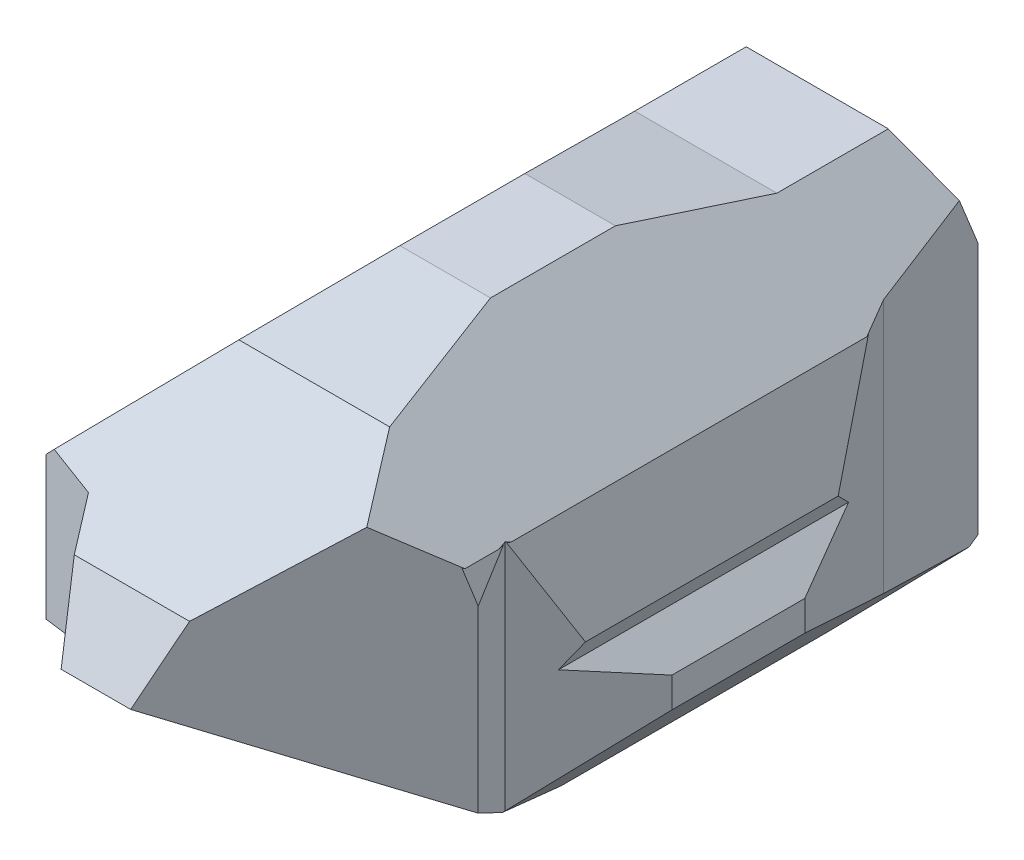
from build123d import *

# Parameters (mm, degrees)
ESQUISSE1_W              = 15
ESQUISSE1_H              = 15
BOSS_EXTRU_1_DEPTH       = 30
ENL_V_MAT_EXTRU_1_DEPTH  = 30
ENL_V_MAT_EXTRU_2_DEPTH  = 30
ENL_V_MAT_EXTRU_3_DEPTH  = 30
ENL_V_MAT_EXTRU_5_DEPTH  = 30
ENL_V_MAT_EXTRU_7_DEPTH  = 30
ENL_V_MAT_EXTRU_8_DEPTH  = 30
ENL_V_MAT_EXTRU_13_DEPTH = 30
ENL_V_MAT_EXTRU_15_DEPTH = 30
ENL_V_MAT_EXTRU_16_DEPTH = 30
ENL_V_MAT_EXTRU_17_DEPTH = 30
ENL_V_MAT_EXTRU_18_DEPTH = 30
ENL_V_MAT_EXTRU_19_DEPTH = 30
ENL_V_MAT_EXTRU_20_DEPTH = 30
ENL_V_MAT_EXTRU_21_DEPTH = 30
ENL_V_MAT_EXTRU_22_DEPTH = 30
ENL_V_MAT_EXTRU_23_DEPTH = 30
ENL_V_MAT_EXTRU_25_DEPTH = 30
ENL_V_MAT_EXTRU_26_DEPTH = 30


with BuildPart() as part:
    # Esquisse1 → Boss.-Extru.1 (new body)
    with BuildSketch(Plane.XY):
        with Locations((7.5, 7.5)):
            Rectangle(ESQUISSE1_W, ESQUISSE1_H)
    extrude(amount=BOSS_EXTRU_1_DEPTH)

    # Esquisse2 → Enlèv. mat.-Extru.1 (cut)
    with BuildSketch(Plane.ZY):
        Polygon((30, 7.5), (17.157208733, 0), (30, 0), align=None)
    extrude(amount=-ENL_V_MAT_EXTRU_1_DEPTH, mode=Mode.SUBTRACT)

    # Esquisse3 → Enlèv. mat.-Extru.2 (cut)
    with BuildSketch(Plane.ZY):
        Polygon((30, 7.5), (28.775513666, 10.065015711), (21.227680677, 15), (30, 15), align=None)
    extrude(amount=-ENL_V_MAT_EXTRU_2_DEPTH, mode=Mode.SUBTRACT)

    # Esquisse4 → Enlèv. mat.-Extru.3 (cut)
    with BuildSketch(Plane.ZY):
        Polygon((8.926273351, 14.031560197), (13.802198678, 15), (0, 15), (0, 5.06907595), (1.662878512, 6.124252415), (3.211780908, 10.370740256), (4.932627015, 14.031560197), align=None)
        Polygon((3.211780908, 1.321204417), (0, 3.148377639), (0, 0), (7.632757812, 0), align=None)
    extrude(amount=-ENL_V_MAT_EXTRU_3_DEPTH, mode=Mode.SUBTRACT)

    # Esquisse5 → Enlèv. mat.-Extru.5 (cut, along a direction that is not the sketch's normal)
    with BuildSketch(Plane(origin=(0, -7.471488968, 4.363238964), x_dir=(-1, 0, 0), z_dir=(0, -0.863533803, 0.504290959))):
        Polygon((-5.951727483, -29.68819628), (-4.385417014, -26.739512451), (-2.316517921, -26.106069571), (-0.765937965, -20.310025776), (-2.831147462, -15.964380335), (-2.523882774, -14.815829705), (0, -14.815829705), (0, -29.68819628), align=None)
    extrude(amount=-ENL_V_MAT_EXTRU_5_DEPTH, dir=(0, -1, 0), mode=Mode.SUBTRACT)

    # Esquisse6 → Enlèv. mat.-Extru.7 (cut)
    with BuildSketch(Plane(origin=(0, 0, 0), x_dir=(-1, 0, 0), z_dir=(0, -1, 0))):
        Polygon((-0.619141534, -13.957767105), (-2.523882774, -17.157208733), (0, -17.157208733), (0, -7.632757812), (-1.718091984, -7.632757812), (-1.06476411, -9.614809502), align=None)
    extrude(amount=-ENL_V_MAT_EXTRU_7_DEPTH, mode=Mode.SUBTRACT)

    # Esquisse8 → Enlèv. mat.-Extru.8 (cut, along a direction that is not the sketch's normal)
    with BuildSketch(Plane(origin=(0, 2.094023155, 0.625796674), x_dir=(1, 0, 0), z_dir=(0, -0.958129282, -0.286335954))):
        Polygon((1.718091984, 7.313168763), (0.628646684, 4.858294572), (1.46050531, 2.698993008), (0, 2.698993008), (0, 7.313168763), align=None)
    extrude(amount=-ENL_V_MAT_EXTRU_8_DEPTH, dir=(0, -1, 0), mode=Mode.SUBTRACT)

    # Esquisse9 → Enlèv. mat.-Extru.13 (cut, along a direction that is not the sketch's normal)
    with BuildSketch(Plane(origin=(0, 2.378568206, 1.353160834), x_dir=(1, 0, 0), z_dir=(0, -0.869189347, -0.494479401))):
        Polygon((9.741570256, -1.177126716), (7.1144792, -1.556807891), (15, -1.556807891), (15, 2.138337382), (14.506645575, 0.943189576), (12.940964542, -0.714733234), align=None)
        Polygon((3.343379322, -0.797445542), (1.46050531, 2.138337382), (0, 2.138337382), (0, -1.556807891), (4.746944503, -1.556807891), align=None)
    extrude(amount=-ENL_V_MAT_EXTRU_13_DEPTH, dir=(0, -1, 0), mode=Mode.SUBTRACT)

    # Esquisse12 → Enlèv. mat.-Extru.15 (cut, along a direction that is not the sketch's normal)
    with BuildSketch(Plane(origin=(0, -7.471488968, 4.363238964), x_dir=(-1, 0, 0), z_dir=(0, -0.863533803, 0.504290959))):
        Polygon((-9.673460517, -29.68819628), (-12.650110774, -26.711546023), (-14.179932039, -24.105910496), (-13.415021407, -19.903610966), (-15, -14.815829705), (-15, -29.68819628), align=None)
    extrude(amount=-ENL_V_MAT_EXTRU_15_DEPTH, dir=(0, -1, 0), mode=Mode.SUBTRACT)

    # Esquisse13 → Enlèv. mat.-Extru.16 (cut)
    with BuildSketch(Plane(origin=(0, 0, 0), x_dir=(-1, 0, 0), z_dir=(0, -1, 0))):
        Polygon((-15, -12.394983272), (-13.060300751, -7.632757812), (-15, -7.632757812), align=None)
    extrude(amount=-ENL_V_MAT_EXTRU_16_DEPTH, mode=Mode.SUBTRACT)

    # Esquisse14 → Enlèv. mat.-Extru.17 (cut, along a direction that is not the sketch's normal)
    with BuildSketch(Plane(origin=(0, 2.094023155, 0.625796674), x_dir=(1, 0, 0), z_dir=(0, -0.958129282, -0.286335954))):
        Polygon((13.060300751, 7.313168763), (12.024477505, 2.698993008), (15, 2.698993008), (15, 7.313168763), align=None)
    extrude(amount=-ENL_V_MAT_EXTRU_17_DEPTH, dir=(0, -1, 0), mode=Mode.SUBTRACT)

    # Esquisse15 → Enlèv. mat.-Extru.18 (cut, along a direction that is not the sketch's normal)
    with BuildSketch(Plane(origin=(0, 2.378568206, 1.353160834), x_dir=(-1, 0, 0), z_dir=(0, -0.869189347, -0.494479401))):
        Polygon((-12.024477505, -2.138337382), (-8.534571531, 1.351568592), (-12.940964542, 0.714733234), (-14.506645575, -0.943189576), (-15, -2.138337382), align=None)
    extrude(amount=-ENL_V_MAT_EXTRU_18_DEPTH, dir=(0, -1, 0), mode=Mode.SUBTRACT)

    # Esquisse16 → Enlèv. mat.-Extru.19 (cut)
    with BuildSketch(Plane(origin=(0, 0, 0), x_dir=(-1, 0, 0), z_dir=(0, 0, -1))):
        Polygon((-15.396052436, 8.861198197), (-9.123900072, 15.526897376), (-16.183146066, 15.526897376), align=None)
    extrude(amount=-ENL_V_MAT_EXTRU_19_DEPTH, mode=Mode.SUBTRACT)

    # Esquisse17 → Enlèv. mat.-Extru.20 (cut)
    with BuildSketch(Plane(origin=(0, 0, 0), x_dir=(-1, 0, 0), z_dir=(0, 0, -1))):
        Polygon((-6.554218331, 15.18646123), (0.669203066, 7.716085255), (0.669203066, 16.0713818), align=None)
    extrude(amount=-ENL_V_MAT_EXTRU_20_DEPTH, mode=Mode.SUBTRACT)

    # Esquisse18 → Enlèv. mat.-Extru.21 (cut)
    with BuildSketch(Plane(origin=(0, 0, 0), x_dir=(-1, 0, 0), z_dir=(0, 0, -1))):
        Polygon((-15, 9.21839227), (-13.921696564, 6.543051012), (-15.506321771, 4.89668716), (-10.237957447, -0.865586318), (-16.387206956, -0.590246788), (-18.552094895, 8.703903566), (-15.878103341, 10.779733946), align=None)
    extrude(amount=-ENL_V_MAT_EXTRU_21_DEPTH, mode=Mode.SUBTRACT)

    # Esquisse19 → Enlèv. mat.-Extru.22 (cut)
    with BuildSketch(Plane(origin=(0, 0, 0), x_dir=(-1, 0, 0), z_dir=(0, 0, -1))):
        Polygon((-5.875093242, -0.721529481), (0.175293911, 5.616971345), (0.854418999, -0.577472644), (-3.508445206, -1.482972763), align=None)
    extrude(amount=-ENL_V_MAT_EXTRU_22_DEPTH, mode=Mode.SUBTRACT)

    # Esquisse20 → Enlèv. mat.-Extru.23 (cut)
    with BuildSketch(Plane.XZ):
        Polygon((14.641535391, 21.431582068), (7.416422476, 31.42072399), (22.821492514, 29.700662918), (19.193376306, 23.52642454), align=None)
    extrude(amount=-ENL_V_MAT_EXTRU_23_DEPTH, mode=Mode.SUBTRACT)

    # Esquisse21 → Enlèv. mat.-Extru.25 (cut)
    with BuildSketch(Plane(origin=(15, 0, 0), x_dir=(0, 0, -1), z_dir=(1, 0, 0))):
        Polygon((-25.251513547, 13.314322934), (-17.635021909, 15.155835068), (-22.650414381, 16.308069891), (-25.79170864, 15.548569091), align=None)
    extrude(amount=-ENL_V_MAT_EXTRU_25_DEPTH, mode=Mode.SUBTRACT)

    # Esquisse22 → Enlèv. mat.-Extru.26 (cut)
    with BuildSketch(Plane(origin=(0, 0, 0), x_dir=(-1, 0, 0), z_dir=(0, 0, -1))):
        Polygon((-14.178463775, 7.180628802), (-13.430249604, 10.918734357), (-15.892886638, 10.134258582), (-16.358917462, 7.805951421), align=None)
    extrude(amount=-ENL_V_MAT_EXTRU_26_DEPTH, mode=Mode.SUBTRACT)


solid = part.part
